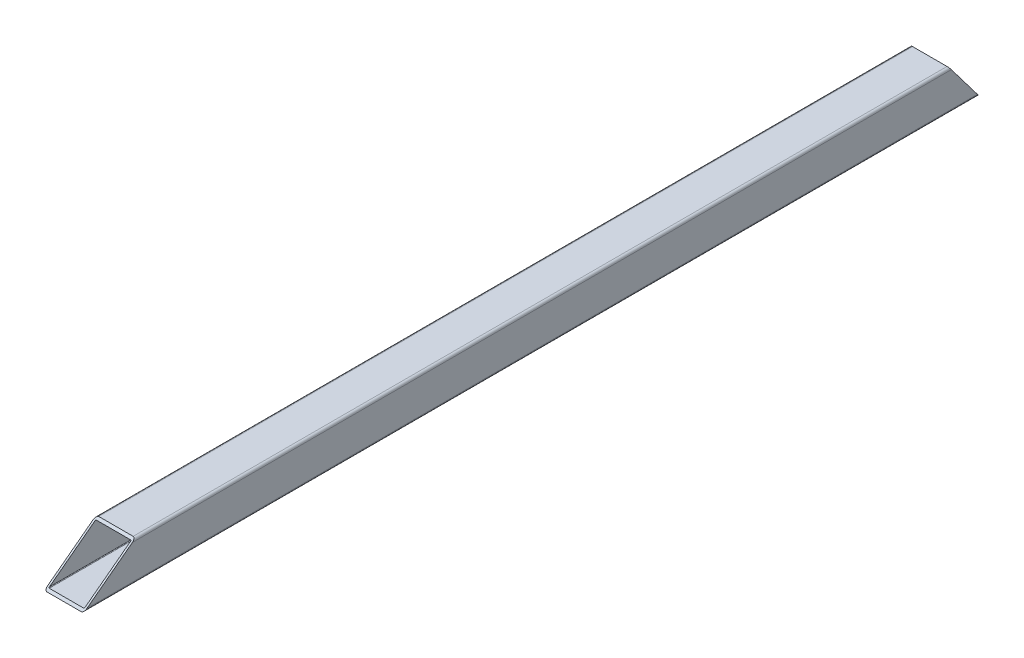
from build123d import *

# Parameters (mm, degrees)
BOSS_EXTRUDE1_DEPTH      = 364.5
BOSS_EXTRUDE1_DEPTH_BACK = 364.5
CUT_EXTRUDE1_DEPTH       = 367.251621157
CUT_EXTRUDE2_DEPTH       = 367.251621157


with BuildPart() as part:
    # Sketch1 → Boss-Extrude1 (new, two sides: drawn at the far end of the back side and taken through both)
    with BuildSketch(Plane.XY.offset(-BOSS_EXTRUDE1_DEPTH_BACK)):
        with BuildLine():
            Line((-14, -16), (14, -16))
            ThreePointArc((14, -16), (15.414213562, -15.414213562), (16, -14))
            Line((16, -14), (16, 14))
            ThreePointArc((16, 14), (15.414213562, 15.414213562), (14, 16))
            Line((14, 16), (-14, 16))
            ThreePointArc((-14, 16), (-15.414213562, 15.414213562), (-16, 14))
            Line((-16, 14), (-16, -14))
            ThreePointArc((-16, -14), (-15.414213562, -15.414213562), (-14, -16))
        make_face()
        with BuildLine():
            Line((-14, 14.48), (14, 14.48))
            ThreePointArc((14, 14.48), (14.339411255, 14.339411255), (14.48, 14))
            Line((14.48, 14), (14.48, -14))
            ThreePointArc((14.48, -14), (14.339411255, -14.339411255), (14, -14.48))
            Line((14, -14.48), (-14, -14.48))
            ThreePointArc((-14, -14.48), (-14.339411255, -14.339411255), (-14.48, -14))
            Line((-14.48, -14), (-14.48, 14))
            ThreePointArc((-14.48, 14), (-14.339411255, 14.339411255), (-14, 14.48))
        make_face(mode=Mode.SUBTRACT)
    extrude(amount=BOSS_EXTRUDE1_DEPTH + BOSS_EXTRUDE1_DEPTH_BACK)

    # Sketch2 → Cut-Extrude1 (cut, through all)
    with BuildSketch(Plane(origin=(16, 0, 0), x_dir=(0, 0, -1), z_dir=(1, 0, 0))):
        Polygon((-364.5, -16), (-364.5, 16), (-322.219100301, 16), align=None)
    extrude(amount=-CUT_EXTRUDE1_DEPTH, mode=Mode.SUBTRACT)

    # Sketch3 → Cut-Extrude2 (cut, through all)
    with BuildSketch(Plane(origin=(16, 0, 0), x_dir=(0, 0, -1), z_dir=(1, 0, 0))):
        Polygon((364.5, 16), (364.5, -16), (340.281026249, 16), align=None)
    extrude(amount=-CUT_EXTRUDE2_DEPTH, mode=Mode.SUBTRACT)


solid = part.part
